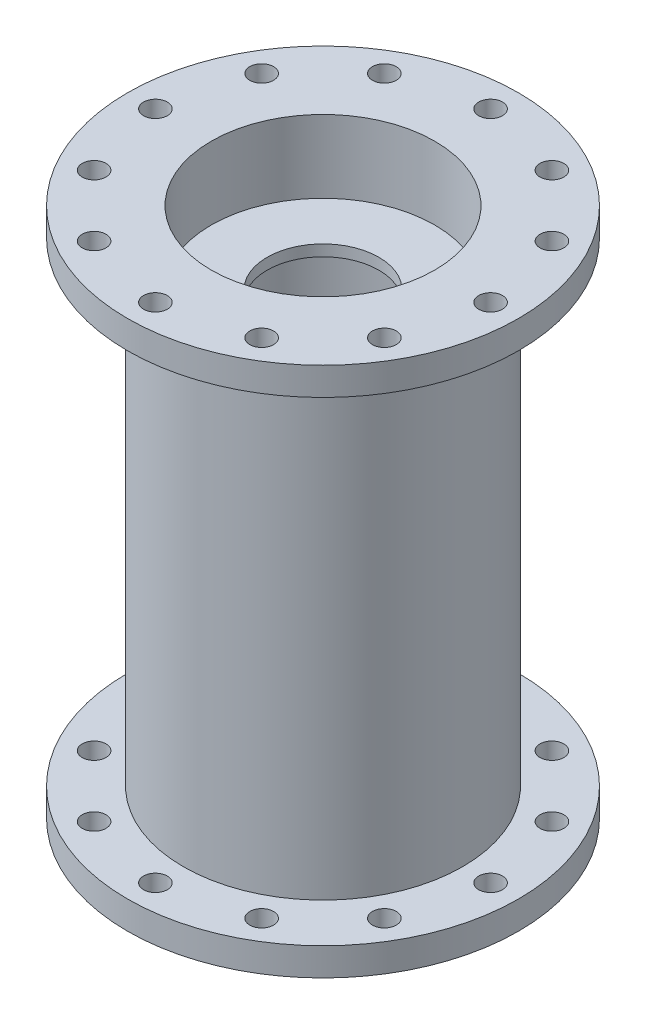
from build123d import *

# Parameters (mm, degrees)
SKETCH4_W                  = 12.7
SKETCH4_H                  = 2.54
F_3_0_213_DIAMETER_HOLE3_D = 5.4102


with BuildPart() as part:
    # Sketch1 → Chamber (revolve)
    with BuildSketch(Plane(origin=(0, 0, 0), x_dir=(0, 0, -1), z_dir=(1, 0, 0))):
        Polygon((31.75, 6.35), (31.75, 114.3), (44.45, 114.3), (44.45, 120.65), (31.75, 120.65), (25.4, 120.65), (25.4, 114.3), (25.4, 6.35), (25.4, 0), (31.75, 0), (44.45, 0), (44.45, 6.35), align=None)
    revolve(axis=Axis((0, 0, 0), (0, 1, 0)))

    # Sketch4 → Turbulence Rings (revolve)
    with BuildSketch(Plane(origin=(0, 0, 0), x_dir=(0, 0, -1), z_dir=(1, 0, 0))):
        with Locations((19.05, 102.87)):
            Rectangle(SKETCH4_W, SKETCH4_H)
        with Locations((19.05, 17.78)):
            Rectangle(SKETCH4_W, SKETCH4_H)
    revolve(axis=Axis((0, 0, 0), (0, 1, 0)))

    # #3 (0.213) Diameter Hole3 (through all)
    with Locations(Plane(origin=(0, 120.65, 0), x_dir=(1, 0, 0), z_dir=(0, 1, 0))):
        with Locations((0, 0), (-38.1, 0), (-32.995567884, 19.05), (-19.05, 32.995567884), (0, 38.1), (19.05, 32.995567884), (32.995567884, 19.05), (38.1, 0), (32.995567884, -19.05), (19.05, -32.995567884), (0, -38.1), (-19.05, -32.995567884), (-32.995567884, -19.05)):
            Hole(F_3_0_213_DIAMETER_HOLE3_D / 2)


solid = part.part
